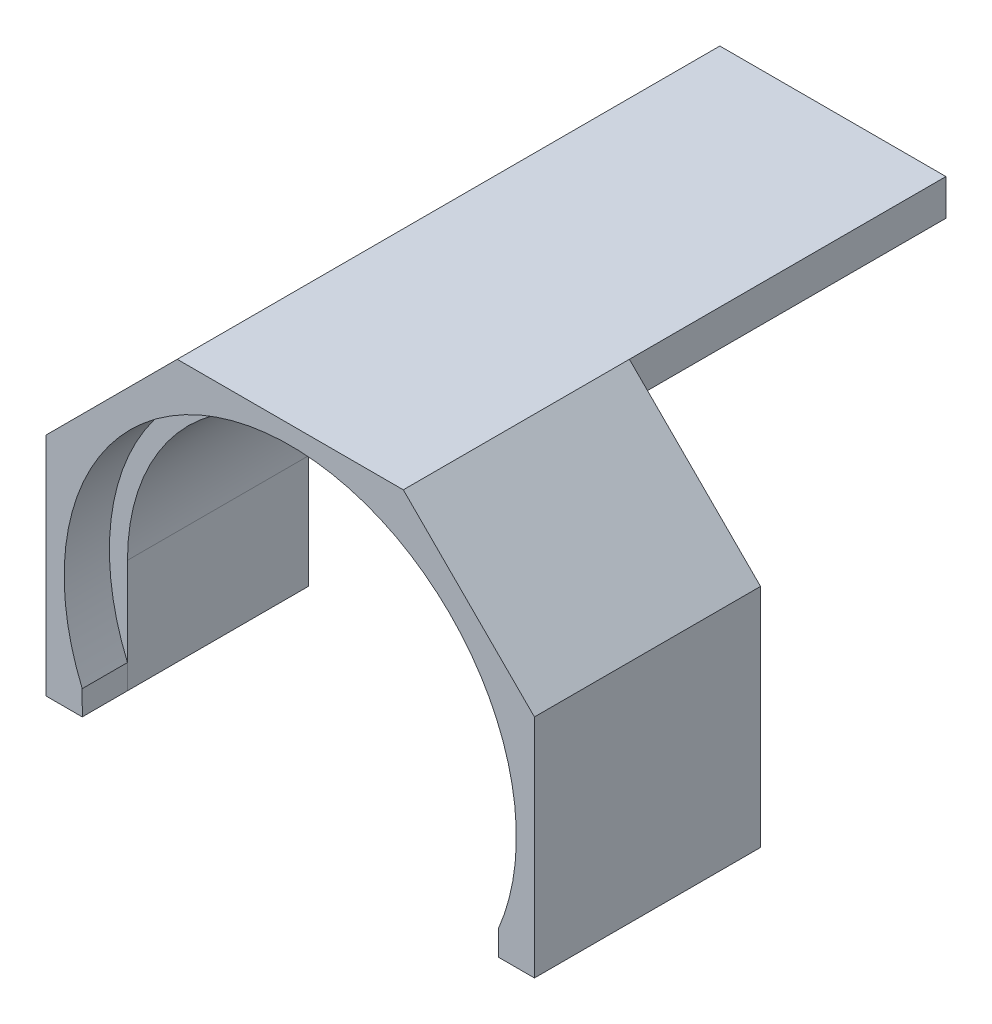
from build123d import *

# Parameters (mm, degrees)
SKETCH_1_W      = 50
SKETCH_1_H      = 8
EXTRUDE_1_DEPTH = 40
EXTRUDE_2_DEPTH = 10


with BuildPart() as part:
    # 扫描1: sweep along a path in 草图2
    with BuildLine(Plane(origin=(0, 0, 0), x_dir=(0, 0, -1), z_dir=(1, 0, 0))) as sweep_1_path:
        Line((0, 55.298323556), (-110, 55.298323556))
    # 草图1 → 扫描1 (sweep)
    with BuildSketch(Plane.XY):
        Rectangle(SKETCH_1_W, SKETCH_1_H)
    sweep(path=sweep_1_path.line)

    # 草图4 → 凸台-拉伸1 (add)
    with BuildSketch(Plane.XY.offset(110)):
        with BuildLine():
            Line((-54, -25), (-25, 4))
            Line((-25, 4), (25, 4))
            Line((25, 4), (54, -25))
            Line((54, -25), (54, -75))
            Line((54, -75), (46, -75))
            Line((46, -75), (46, -50))
            ThreePointArc((46, -50), (0, -4), (-46, -50))
            Line((-46, -50), (-46, -75))
            Line((-46, -75), (-54, -75))
            Line((-54, -75), (-54, -25))
        make_face()
    extrude(amount=-EXTRUDE_1_DEPTH)

    # 草图5 → 凸台-拉伸2 (add)
    with BuildSketch(Plane.XY.offset(110)):
        with BuildLine():
            Line((-46.0046646, -69.584964515), (-46, -75))
            Line((-46, -75), (-54, -75))
            Line((-54, -75), (-54, -25))
            Line((-54, -25), (-25, 4))
            Line((-25, 4), (25, 4))
            Line((25, 4), (54, -25))
            Line((54, -25), (54, -75))
            Line((54, -75), (46, -75))
            Line((46, -75), (46, -69.595917942))
            ThreePointArc((46, -69.595917942), (0.005952648, -3.54e-07), (-46.0046646, -69.584964515))
        make_face()
    extrude(amount=EXTRUDE_2_DEPTH)


solid = part.part
